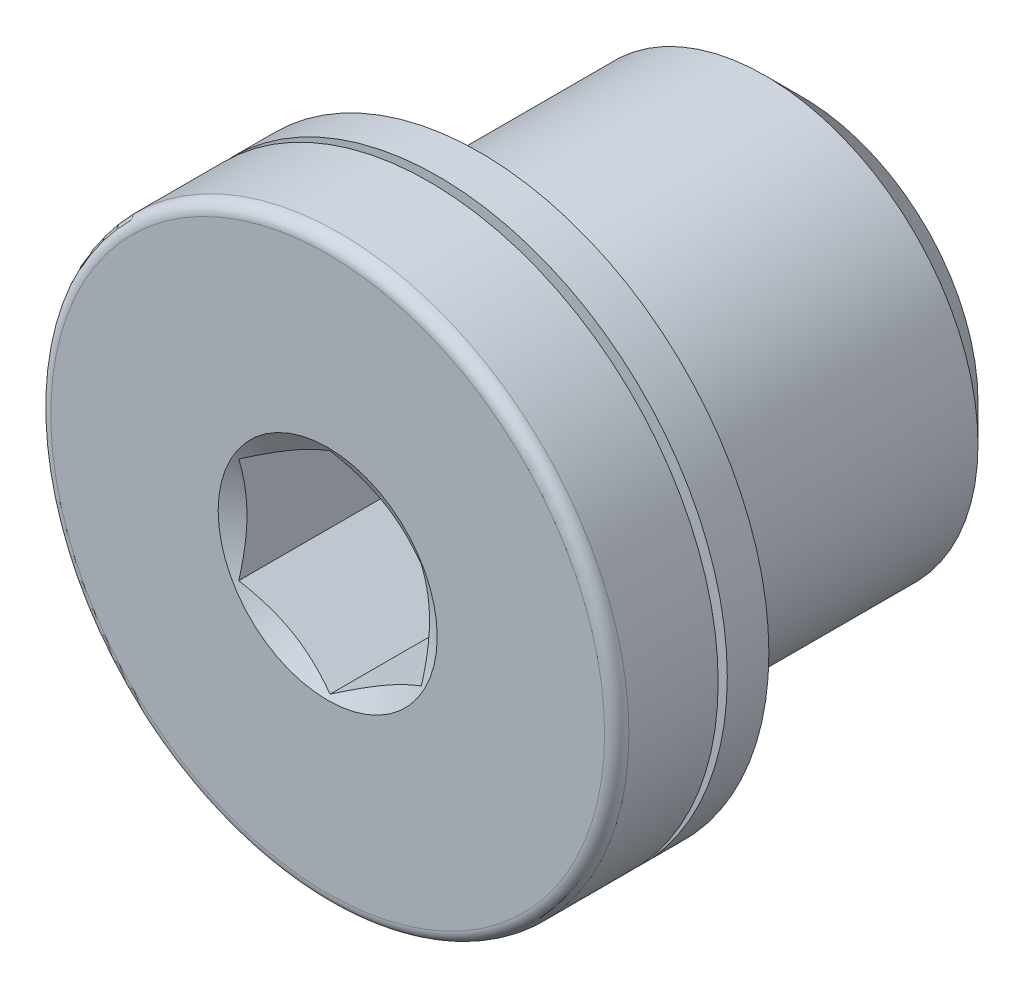
from build123d import *

# Parameters (mm, degrees)
CUT_EXTRUDE1_DEPTH = 2.5


with BuildPart() as part:
    # Sketch1 → Revolve1 (revolve)
    with BuildSketch(Plane(origin=(0, 0, 0), x_dir=(0, 0, -1), z_dir=(1, 0, 0))):
        with BuildLine():
            Line((-1.460769515, 0), (-2.5, 1.8))
            Line((-2.5, 1.8), (-2.5, 4.55))
            ThreePointArc((-2.5, 4.55), (-2.441421356, 4.691421356), (-2.3, 4.75))
            Line((-2.3, 4.75), (-0.833333333, 4.75))
            Line((-0.833333333, 4.75), (-0.833333333, 4.275))
            Line((-0.833333333, 4.275), (-0.683333333, 4.275))
            Line((-0.683333333, 4.275), (-0.683333333, 4.75))
            Line((-0.683333333, 4.75), (0, 4.75))
            Line((0, 4.75), (0, 2.8865))
            Line((0, 2.8865), (0.6135, 3.5))
            Line((0.6135, 3.5), (4.6865, 3.5))
            Line((4.6865, 3.5), (5.3, 2.8865))
            Line((5.3, 2.8865), (5.3, 0))
            Line((5.3, 0), (-1.460769515, 0))
        make_face()
    revolve(axis=Axis((0, 0, -5.3), (0, 0, 1)))

    # Sketch2 → Cut-Extrude1 (cut)
    with BuildSketch(Plane.XY.offset(2.5)):
        Polygon((-1.5, -0.866025404), (0, -1.732050808), (1.5, -0.866025404), (1.5, 0.866025404), (0, 1.732050808), (-1.5, 0.866025404), align=None)
    extrude(amount=-CUT_EXTRUDE1_DEPTH, mode=Mode.SUBTRACT)


solid = part.part
